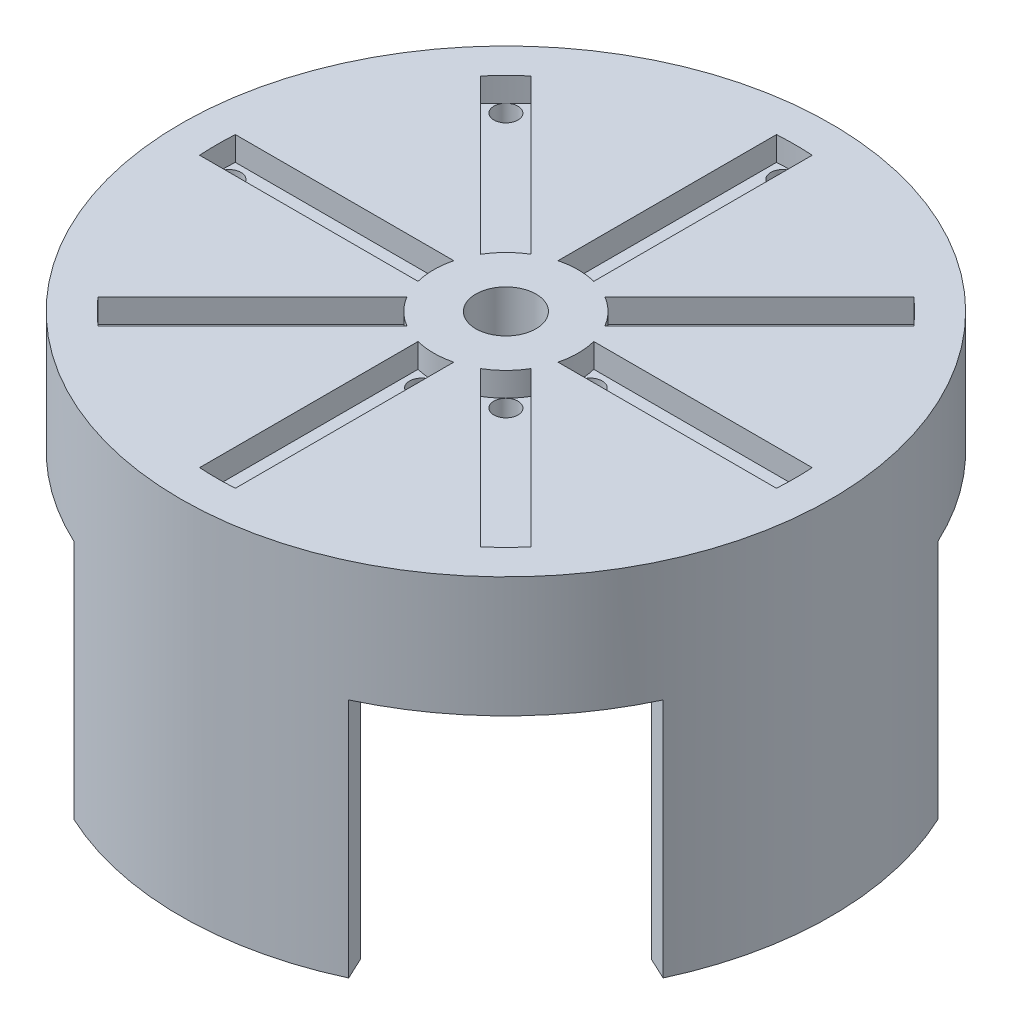
from build123d import *
from build123d.topology import SkipClean

# Parameters (mm, degrees)
SKETCH_1_R               = 27
EXTRUDE_1_DEPTH          = 10
SKETCH_2_R               = 2.5
CUT_EXTRUDE_1_DEPTH      = 15
EXTRUDE_START            = 20
EXTRUDE_2_DEPTH          = 20
CUT_EXTRUDE_2_DEPTH      = 2
CUT_EXTRUDE_3_DEPTH      = 37
CUT_EXTRUDE_3_DEPTH_BACK = 37
SKETCH_5_R               = 1


with BuildPart() as part:
    # Эскиз1 → Бобышка-Вытянуть1 (new body)
    with BuildSketch(Plane(origin=(0, 0, 0), x_dir=(1, 0, 0), z_dir=(0, 1, 0))):
        Circle(SKETCH_1_R)
    extrude(amount=EXTRUDE_1_DEPTH)

    # Эскиз2 → Вырез-Вытянуть1 (cut)
    with BuildSketch(Plane(origin=(0, 10, 0), x_dir=(1, 0, 0), z_dir=(0, 1, 0))):
        Circle(SKETCH_2_R)
    extrude(amount=-CUT_EXTRUDE_1_DEPTH, mode=Mode.SUBTRACT)

    # Эскиз3 → Бобышка-Вытянуть2 (add)
    with SkipClean():  # the faces are left unmerged after this step: merging them gives an invalid solid
        with BuildSketch(Plane.XZ.offset(EXTRUDE_START)):
            with BuildLine():
                Line((-11.410693066, 24.47031025), (-10.565456543, 22.657694676))
                ThreePointArc((-10.565456543, 22.657694676), (1e-09, 25), (10.565456544, 22.657694676))
                Line((10.565456544, 22.657694676), (11.410693067, 24.47031025))
                ThreePointArc((11.410693067, 24.47031025), (1e-09, 27), (-11.410693066, 24.47031025))
            make_face()
            with BuildLine():
                Line((24.47031025, 11.410693066), (22.657694676, 10.565456543))
                ThreePointArc((22.657694676, 10.565456543), (25, -1e-09), (22.657694676, -10.565456544))
                Line((22.657694676, -10.565456544), (24.47031025, -11.410693067))
                ThreePointArc((24.47031025, -11.410693067), (27, -1e-09), (24.47031025, 11.410693066))
            make_face()
            with BuildLine():
                Line((11.410693066, -24.47031025), (10.565456543, -22.657694676))
                ThreePointArc((10.565456543, -22.657694676), (-1e-09, -25), (-10.565456544, -22.657694676))
                Line((-10.565456544, -22.657694676), (-11.410693067, -24.47031025))
                ThreePointArc((-11.410693067, -24.47031025), (-1e-09, -27), (11.410693066, -24.47031025))
            make_face()
            with BuildLine():
                Line((-24.47031025, -11.410693066), (-22.657694676, -10.565456543))
                ThreePointArc((-22.657694676, -10.565456543), (-25, 1e-09), (-22.657694676, 10.565456544))
                Line((-22.657694676, 10.565456544), (-24.47031025, 11.410693067))
                ThreePointArc((-24.47031025, 11.410693067), (-27, 1e-09), (-24.47031025, -11.410693066))
            make_face()
        extrude(amount=-EXTRUDE_2_DEPTH)

    # Эскиз4 → Вырез-Вытянуть2 (cut)
    with SkipClean():  # the faces are left unmerged after this step: merging them gives an invalid solid
        with BuildSketch(Plane(origin=(0, 10, 0), x_dir=(1, 0, 0), z_dir=(0, 1, 0))):
            with BuildLine():
                Line((-17.988048884, 15.888048884), (-5.160656882, 3.060656882))
                ThreePointArc((-5.160656882, 3.060656882), (-4.242640687, 4.242640687), (-3.060656882, 5.160656882))
                Line((-3.060656882, 5.160656882), (-15.888048884, 17.988048884))
                ThreePointArc((-15.888048884, 17.988048884), (-16.970562748, 16.970562748), (-17.988048884, 15.888048884))
            make_face()
            with BuildLine():
                Line((1.48492424, 23.954018452), (1.48492424, 5.813346713))
                ThreePointArc((1.48492424, 5.813346713), (0, 6), (-1.484924241, 5.813346713))
                Line((-1.484924241, 5.813346713), (-1.484924241, 23.954018452))
                ThreePointArc((-1.484924241, 23.954018452), (0, 24), (1.48492424, 23.954018452))
            make_face()
            with BuildLine():
                Line((17.988048884, 15.888048884), (5.160656882, 3.060656882))
                ThreePointArc((5.160656882, 3.060656882), (4.242640687, 4.242640687), (3.060656882, 5.160656882))
                Line((3.060656882, 5.160656882), (15.888048884, 17.988048884))
                ThreePointArc((15.888048884, 17.988048884), (16.970562748, 16.970562748), (17.988048884, 15.888048884))
            make_face()
            with BuildLine():
                Line((23.954018452, -1.48492424), (5.813346713, -1.48492424))
                ThreePointArc((5.813346713, -1.48492424), (6, 0), (5.813346713, 1.484924241))
                Line((5.813346713, 1.484924241), (23.954018452, 1.484924241))
                ThreePointArc((23.954018452, 1.484924241), (24, 0), (23.954018452, -1.48492424))
            make_face()
            with BuildLine():
                Line((15.888048884, -17.988048884), (3.060656882, -5.160656882))
                ThreePointArc((3.060656882, -5.160656882), (4.242640687, -4.242640687), (5.160656882, -3.060656882))
                Line((5.160656882, -3.060656882), (17.988048884, -15.888048884))
                ThreePointArc((17.988048884, -15.888048884), (16.970562748, -16.970562748), (15.888048884, -17.988048884))
            make_face()
            with BuildLine():
                Line((-1.48492424, -23.954018452), (-1.48492424, -5.813346713))
                ThreePointArc((-1.48492424, -5.813346713), (0, -6), (1.484924241, -5.813346713))
                Line((1.484924241, -5.813346713), (1.484924241, -23.954018452))
                ThreePointArc((1.484924241, -23.954018452), (0, -24), (-1.48492424, -23.954018452))
            make_face()
            with BuildLine():
                Line((-17.988048884, -15.888048884), (-5.160656882, -3.060656882))
                ThreePointArc((-5.160656882, -3.060656882), (-4.242640687, -4.242640687), (-3.060656882, -5.160656882))
                Line((-3.060656882, -5.160656882), (-15.888048884, -17.988048884))
                ThreePointArc((-15.888048884, -17.988048884), (-16.970562748, -16.970562748), (-17.988048884, -15.888048884))
            make_face()
            with BuildLine():
                Line((-23.954018452, 1.48492424), (-5.813346713, 1.48492424))
                ThreePointArc((-5.813346713, 1.48492424), (-6, 0), (-5.813346713, -1.484924241))
                Line((-5.813346713, -1.484924241), (-23.954018452, -1.484924241))
                ThreePointArc((-23.954018452, -1.484924241), (-24, 0), (-23.954018452, 1.48492424))
            make_face()
        extrude(amount=-CUT_EXTRUDE_2_DEPTH, mode=Mode.SUBTRACT)

    # Эскиз5 → Вырез-Вытянуть3 (cut, two sides: drawn at the far end of the back side and taken through both)
    with SkipClean():  # the faces are left unmerged after this step: merging them gives an invalid solid
        with BuildSketch(Plane(origin=(0, 10, 0), x_dir=(1, 0, 0), z_dir=(0, 1, 0)).offset(-CUT_EXTRUDE_3_DEPTH_BACK)):
            with Locations((-7, 0)):
                Circle(SKETCH_5_R)
            with Locations((-23, 0)):
                Circle(SKETCH_5_R)
            with Locations((-16.263455967, 16.263455967)):
                Circle(SKETCH_5_R)
            with Locations((-4.949747468, 4.949747468)):
                Circle(SKETCH_5_R)
            with Locations((0, 23)):
                Circle(SKETCH_5_R)
            with Locations((0, 7)):
                Circle(SKETCH_5_R)
            with Locations((16.263455967, 16.263455967)):
                Circle(SKETCH_5_R)
            with Locations((4.949747468, 4.949747468)):
                Circle(SKETCH_5_R)
            with Locations((23, 0)):
                Circle(SKETCH_5_R)
            with Locations((7, 0)):
                Circle(SKETCH_5_R)
            with Locations((16.263455967, -16.263455967)):
                Circle(SKETCH_5_R)
            with Locations((4.949747468, -4.949747468)):
                Circle(SKETCH_5_R)
            with Locations((0, -23)):
                Circle(SKETCH_5_R)
            with Locations((0, -7)):
                Circle(SKETCH_5_R)
            with Locations((-16.263455967, -16.263455967)):
                Circle(SKETCH_5_R)
            with Locations((-4.949747468, -4.949747468)):
                Circle(SKETCH_5_R)
        extrude(amount=CUT_EXTRUDE_3_DEPTH + CUT_EXTRUDE_3_DEPTH_BACK, mode=Mode.SUBTRACT)


solid = part.part
